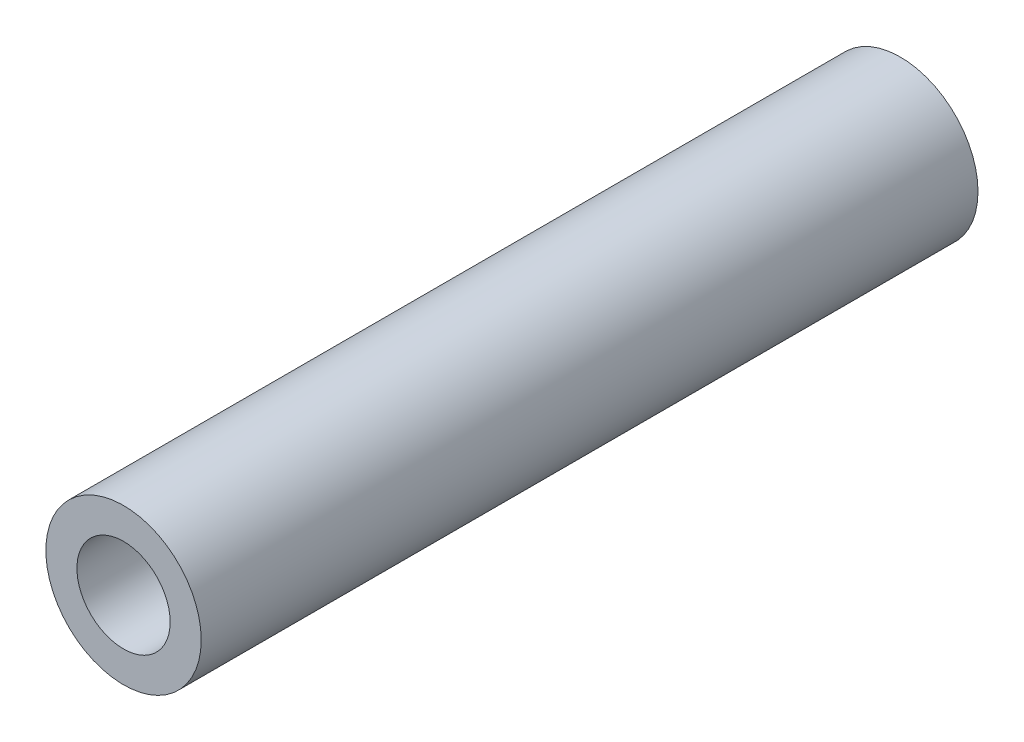
from build123d import *

# Parameters (mm, degrees)
SKETCH_1_R      = 2.5
SKETCH_1_R_2    = 1.5
EXTRUDE_1_DEPTH = 12.5


with BuildPart() as part:
    # 草图1 → 凸台-拉伸1 (new body, symmetric)
    with BuildSketch(Plane.XY):
        Circle(SKETCH_1_R)
        Circle(SKETCH_1_R_2, mode=Mode.SUBTRACT)
    extrude(amount=EXTRUDE_1_DEPTH, both=True)


solid = part.part
